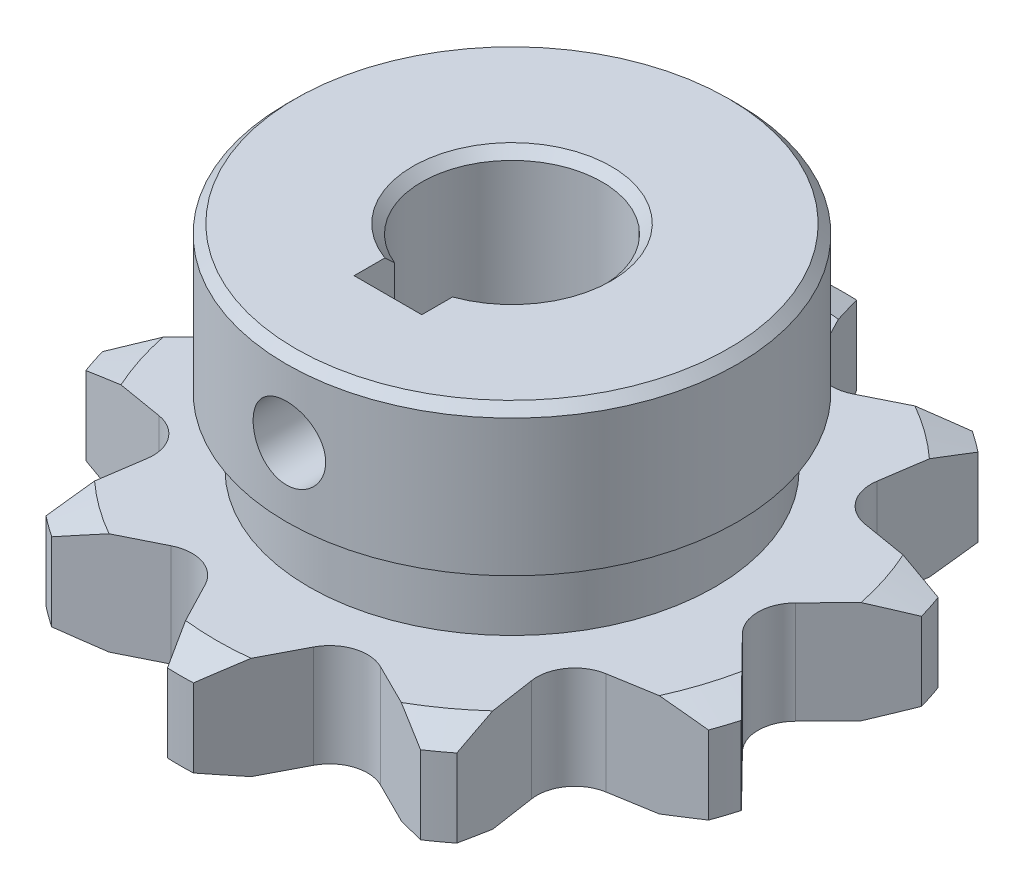
from build123d import *

# Parameters (mm, degrees)
SALIENTE_EXTRUIR1_DEPTH = 7.2136
CROQUIS2_R              = 15.875
SALIENTE_EXTRUIR2_DEPTH = 15.0114
CROQUIS5_R              = 6.35
CORTAR_EXTRUIR2_DEPTH   = 23.2250001
CHAFL_N2_SIZE           = 0.635
REDONDEO1_R             = 0.635
CROQUIS8_W              = 3.175
CROQUIS8_H              = 4.7625
CROQUIS9_W              = 2.5527
CROQUIS9_H              = 15.875
CHAFL_N3_SIZE           = 0.635
CROQUIS11_W             = 4.7625
CROQUIS11_H             = 4.7625
CORTAR_EXTRUIR3_DEPTH   = 23.225


with BuildPart() as part:
    # Croquis1 → Saliente-Extruir1 (new body)
    with BuildSketch(Plane(origin=(0, 0, 0), x_dir=(1, 0, 0), z_dir=(0, 1, 0))):
        with BuildLine():
            Line((12.977610276, 19.417818353), (7.368467037, 16.623783971))
            ThreePointArc((7.368467037, 16.623783971), (5.352847667, 16.474371141), (3.81, 17.78))
            Line((3.81, 17.78), (0.9144, 23.337392972))
            ThreePointArc((0.9144, 23.337392972), (0, 23.3553), (-0.9144, 23.337392972))
            Line((-0.9144, 23.337392972), (-3.81, 17.78))
            ThreePointArc((-3.81, 17.78), (-5.352847667, 16.474371141), (-7.368467037, 16.623783971))
            Line((-7.368467037, 16.623783971), (-12.977610276, 19.417818353))
            ThreePointArc((-12.977610276, 19.417818353), (-13.727900903, 18.894834609), (-14.457140556, 18.342876684))
            Line((-14.457140556, 18.342876684), (-13.533176534, 12.144860349))
            ThreePointArc((-13.533176534, 12.144860349), (-14.013937128, 10.181721309), (-15.732430111, 9.117847487))
            Line((-15.732430111, 9.117847487), (-21.91261452, 8.081297111))
            ThreePointArc((-21.91261452, 8.081297111), (-22.212210255, 7.217184609), (-22.477744799, 6.342004954))
            Line((-22.477744799, 6.342004954), (-18.087139608, 1.870796833))
            ThreePointArc((-18.087139608, 1.870796833), (-17.322178923, 0), (-18.087139608, -1.870796833))
            Line((-18.087139608, -1.870796833), (-22.477744799, -6.342004954))
            ThreePointArc((-22.477744799, -6.342004954), (-22.212210255, -7.217184609), (-21.91261452, -8.081297111))
            Line((-21.91261452, -8.081297111), (-15.732430111, -9.117847487))
            ThreePointArc((-15.732430111, -9.117847487), (-14.013937128, -10.181721309), (-13.533176534, -12.144860349))
            Line((-13.533176534, -12.144860349), (-14.457140556, -18.342876684))
            ThreePointArc((-14.457140556, -18.342876684), (-13.727900903, -18.894834609), (-12.977610276, -19.417818353))
            Line((-12.977610276, -19.417818353), (-7.368467037, -16.623783971))
            ThreePointArc((-7.368467037, -16.623783971), (-5.352847667, -16.474371141), (-3.81, -17.78))
            Line((-3.81, -17.78), (-0.9144, -23.337392972))
            ThreePointArc((-0.9144, -23.337392972), (0, -23.3553), (0.9144, -23.337392972))
            Line((0.9144, -23.337392972), (3.81, -17.78))
            ThreePointArc((3.81, -17.78), (5.352847667, -16.474371141), (7.368467037, -16.623783971))
            Line((7.368467037, -16.623783971), (12.977610276, -19.417818353))
            ThreePointArc((12.977610276, -19.417818353), (13.727900903, -18.894834609), (14.457140556, -18.342876684))
            Line((14.457140556, -18.342876684), (13.533176534, -12.144860349))
            ThreePointArc((13.533176534, -12.144860349), (14.013937128, -10.181721309), (15.732430111, -9.117847487))
            Line((15.732430111, -9.117847487), (21.91261452, -8.081297111))
            ThreePointArc((21.91261452, -8.081297111), (22.212210255, -7.217184609), (22.477744799, -6.342004954))
            Line((22.477744799, -6.342004954), (18.087139608, -1.870796833))
            ThreePointArc((18.087139608, -1.870796833), (17.322178923, 0), (18.087139608, 1.870796833))
            Line((18.087139608, 1.870796833), (22.477744799, 6.342004954))
            ThreePointArc((22.477744799, 6.342004954), (22.212210255, 7.217184609), (21.91261452, 8.081297111))
            Line((21.91261452, 8.081297111), (15.732430111, 9.117847487))
            ThreePointArc((15.732430111, 9.117847487), (14.013937128, 10.181721309), (13.533176534, 12.144860349))
            Line((13.533176534, 12.144860349), (14.457140556, 18.342876684))
            ThreePointArc((14.457140556, 18.342876684), (13.727900903, 18.894834609), (12.977610276, 19.417818353))
        make_face()
    extrude(amount=SALIENTE_EXTRUIR1_DEPTH)

    # Croquis2 → Saliente-Extruir2 (add)
    with BuildSketch(Plane(origin=(0, 7.2136, 0), x_dir=(1, 0, 0), z_dir=(0, 1, 0))):
        Circle(CROQUIS2_R)
    extrude(amount=SALIENTE_EXTRUIR2_DEPTH)

    # Croquis3 → Cortar-Revolución3 (revolve, cut)
    with BuildSketch(Plane(origin=(0, 0, 0), x_dir=(0, 0, -1), z_dir=(1, 0, 0))):
        Polygon((23.972392972, 7.2136), (23.972392972, 6.1468), (20.797392972, 7.2136), align=None)
    cortar_revoluci_n3 = revolve(axis=Axis((0, 0, 0), (0, -1, 0)), mode=Mode.SUBTRACT)

    # Simetría1: Cortar-Revolución3 across plane
    add(cortar_revoluci_n3.mirror(Plane.ZX.offset(3.6068)), mode=Mode.SUBTRACT)

    # Croquis5 → Cortar-Extruir2 (cut, through all)
    with BuildSketch(Plane(origin=(0, 22.225, 0), x_dir=(1, 0, 0), z_dir=(0, 1, 0))):
        Circle(CROQUIS5_R)
    extrude(amount=-CORTAR_EXTRUIR2_DEPTH, mode=Mode.SUBTRACT)

    # Chaflán2
    chafl_n2_edges = [part.edges().sort_by_distance(p)[0] for p in [
        (-15.875, 22.225, 0),
    ]]
    chamfer(chafl_n2_edges, length=CHAFL_N2_SIZE)

    # Redondeo1
    redondeo1_edges = [part.edges().sort_by_distance(p)[0] for p in [
        (-15.875, 7.2136, 0),
    ]]
    fillet(redondeo1_edges, radius=REDONDEO1_R)

    # Croquis8 → Cortar-Revolución4 (revolve, cut)
    with BuildSketch(Plane(origin=(0, 0, 0), x_dir=(0, 0, -1), z_dir=(1, 0, 0))):
        with Locations((-15.870465895, 9.59485)):
            Rectangle(CROQUIS8_W, CROQUIS8_H)
    revolve(axis=Axis((0, 0, -0.004534105), (0, -1, 0)), mode=Mode.SUBTRACT)

    # Croquis9 → Taladro roscado 1/4-201 (revolve, cut)
    with BuildSketch(Plane(origin=(0, 16.78305, 0), x_dir=(0, 1, 0), z_dir=(1, 0, 0))):
        with Locations((1.27635, 7.9375)):
            Rectangle(CROQUIS9_W, CROQUIS9_H)
    revolve(axis=Axis((0, 16.78305, -6.35), (0, 0, 1)), mode=Mode.SUBTRACT)

    # Chaflán3
    chafl_n3_edges = [part.edges().sort_by_distance(p)[0] for p in [
        (-6.35, 0, 0),
        (-6.35, 22.225, 0),
    ]]
    chamfer(chafl_n3_edges, length=CHAFL_N3_SIZE)

    # Croquis11 → Cortar-Extruir3 (cut, through all)
    with BuildSketch(Plane.XZ):
        with Locations((0, 6.35)):
            Rectangle(CROQUIS11_W, CROQUIS11_H)
    extrude(amount=-CORTAR_EXTRUIR3_DEPTH, mode=Mode.SUBTRACT)


solid = part.part
